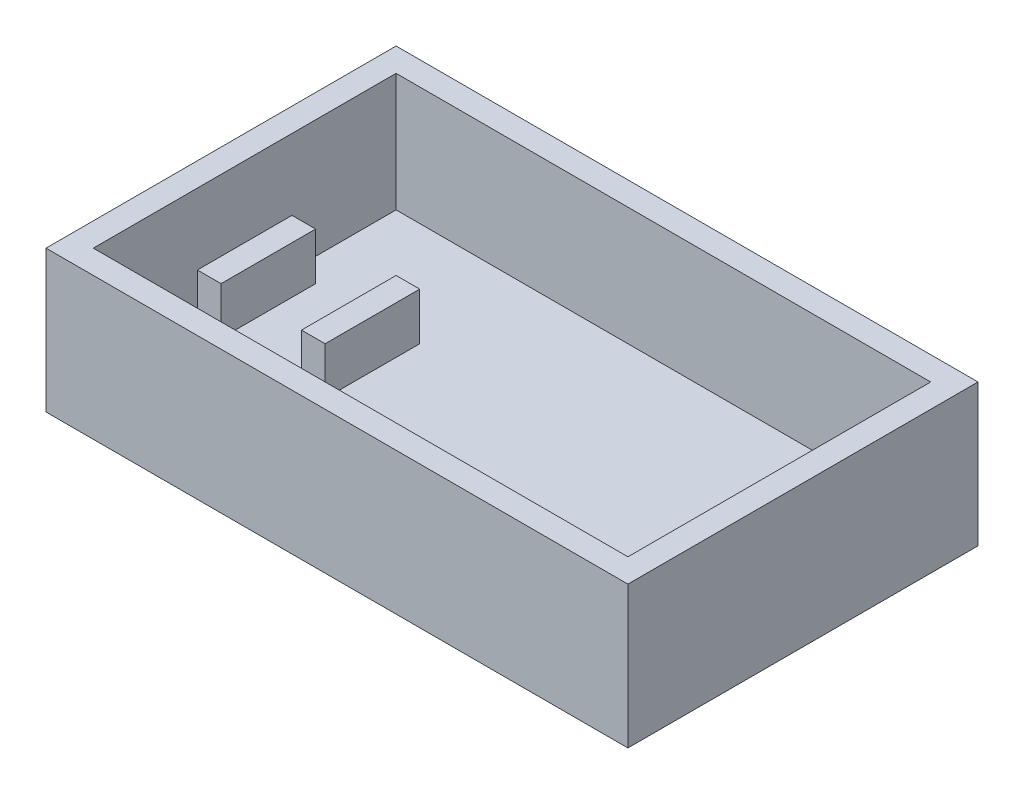
from build123d import *

# Parameters (mm, degrees)
SKETCH1_W           = 123
SKETCH1_H           = 74
BOSS_EXTRUDE1_DEPTH = 30
SKETCH2_W           = 113
SKETCH2_H           = 64
CUT_EXTRUDE1_DEPTH  = 25
BOSS_EXTRUDE2_DEPTH = 10
LPATTERN1_COUNT     = 2
LPATTERN1_PITCH     = 22


with BuildPart() as part:
    # Sketch1 → Boss-Extrude1 (new body)
    with BuildSketch(Plane(origin=(0, 0, 0), x_dir=(1, 0, 0), z_dir=(0, 1, 0))):
        Rectangle(SKETCH1_W, SKETCH1_H)
    extrude(amount=BOSS_EXTRUDE1_DEPTH)

    # Sketch2 → Cut-Extrude1 (cut)
    with BuildSketch(Plane(origin=(0, 30, 0), x_dir=(1, 0, 0), z_dir=(0, 1, 0))):
        Rectangle(SKETCH2_W, SKETCH2_H)
    extrude(amount=-CUT_EXTRUDE1_DEPTH, mode=Mode.SUBTRACT)

    # Sketch4 → Boss-Extrude2 (add)
    with BuildSketch(Plane(origin=(0, 5, 0), x_dir=(1, 0, 0), z_dir=(0, 1, 0))):
        Polygon((-56.5, -10), (-51.5, -10), (-51.5, 10), (-56.5, 10), (-56.5, 0), align=None)
    boss_extrude2 = extrude(amount=BOSS_EXTRUDE2_DEPTH)

    # LPattern1: Boss-Extrude2 ×2
    with Locations(*[(i * LPATTERN1_PITCH, 0, 0) for i in range(1, LPATTERN1_COUNT)]):
        add(boss_extrude2)


solid = part.part
